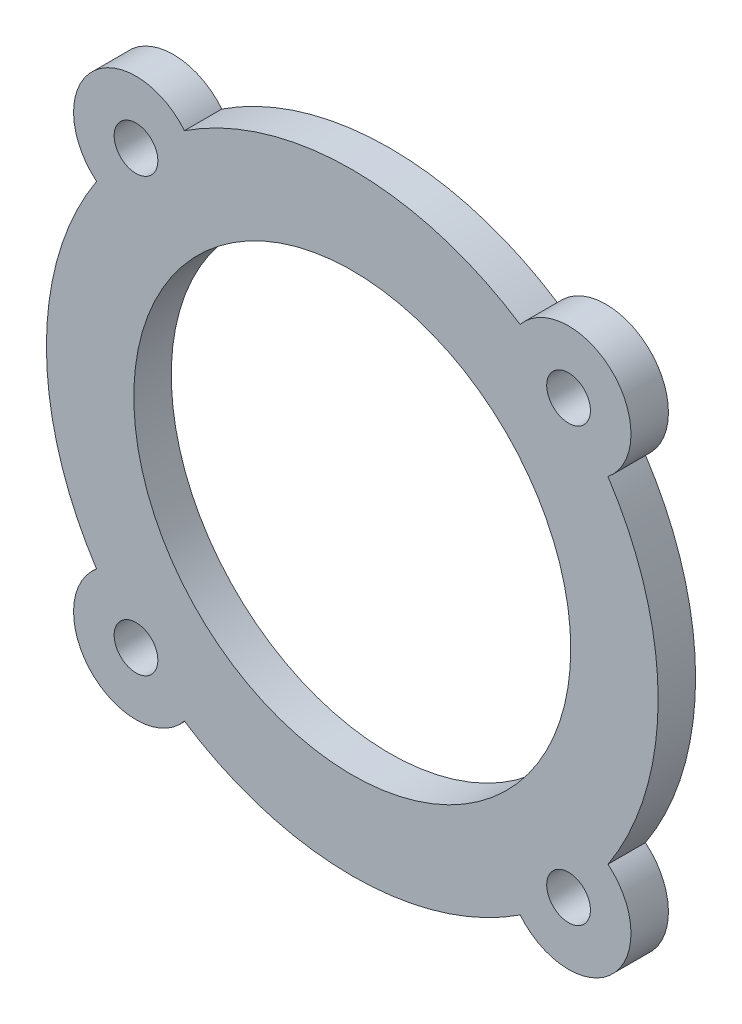
from build123d import *

# Parameters (mm, degrees)
SKETCH_1_R      = 17.5
SKETCH_1_R_2    = 1.75
EXTRUDE_1_DEPTH = 3


with BuildPart() as part:
    # 草图1 → 凸台-拉伸1 (new body)
    with BuildSketch(Plane.XY):
        with BuildLine():
            ThreePointArc((-13.446268202, 20.480426545), (-20.859650045, 20.859650045), (-20.480426545, 13.446268202))
            ThreePointArc((-20.480426545, 13.446268202), (-24.5, 0), (-20.480426545, -13.446268202))
            ThreePointArc((-20.480426545, -13.446268202), (-20.859650045, -20.859650045), (-13.446268202, -20.480426545))
            ThreePointArc((-13.446268202, -20.480426545), (0, -24.5), (13.446268202, -20.480426545))
            ThreePointArc((13.446268202, -20.480426545), (20.859650045, -20.859650045), (20.480426545, -13.446268202))
            ThreePointArc((20.480426545, -13.446268202), (24.5, 0), (20.480426545, 13.446268202))
            ThreePointArc((20.480426545, 13.446268202), (20.859650045, 20.859650045), (13.446268202, 20.480426545))
            ThreePointArc((13.446268202, 20.480426545), (0, 24.5), (-13.446268202, 20.480426545))
        make_face()
        Circle(SKETCH_1_R, mode=Mode.SUBTRACT)
        with Locations((-17.324116139, 17.324116139)):
            Circle(SKETCH_1_R_2, mode=Mode.SUBTRACT)
        with Locations((17.324116139, 17.324116139)):
            Circle(SKETCH_1_R_2, mode=Mode.SUBTRACT)
        with Locations((17.324116139, -17.324116139)):
            Circle(SKETCH_1_R_2, mode=Mode.SUBTRACT)
        with Locations((-17.324116139, -17.324116139)):
            Circle(SKETCH_1_R_2, mode=Mode.SUBTRACT)
    extrude(amount=EXTRUDE_1_DEPTH)


solid = part.part
